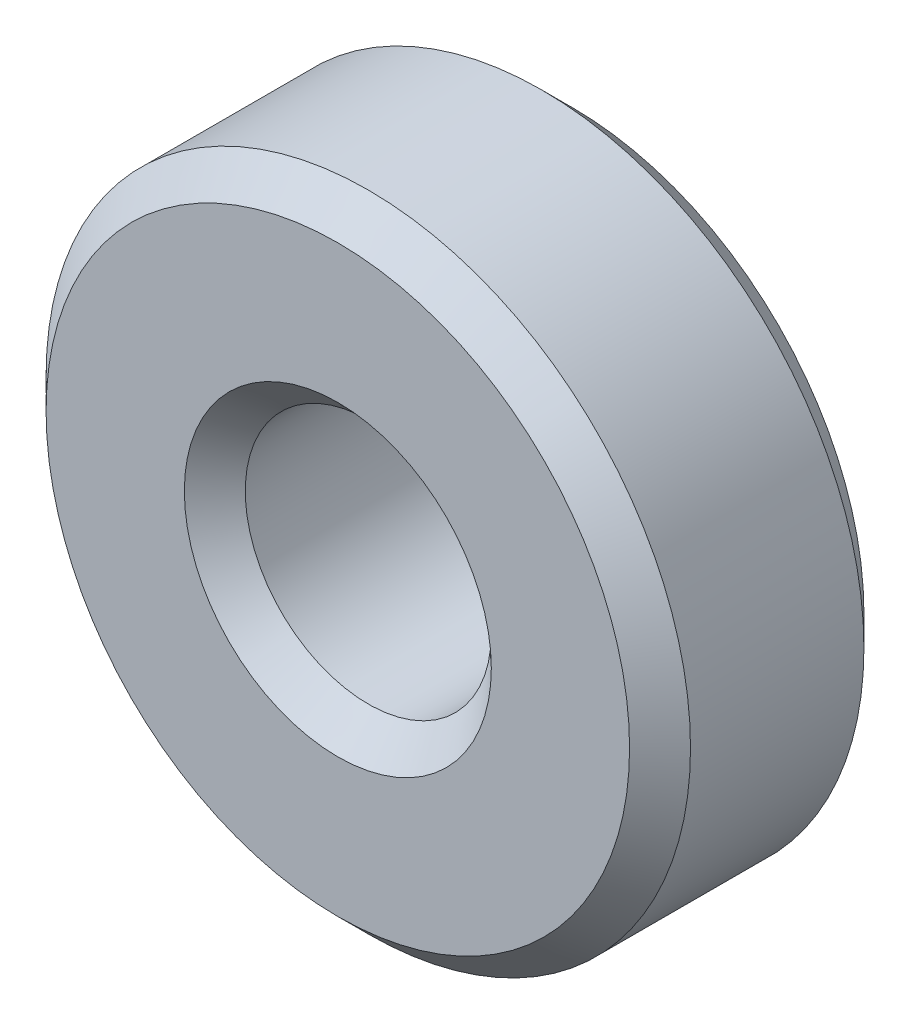
from build123d import *

# Parameters (mm, degrees)
SKETCH1_R           = 6.875
SKETCH1_R_2         = 2.625
BOSS_EXTRUDE1_DEPTH = 5
CHAMFER1_SIZE       = 0.65


with BuildPart() as part:
    # Sketch1 → Boss-Extrude1 (new body)
    with BuildSketch(Plane.XY):
        Circle(SKETCH1_R)
        Circle(SKETCH1_R_2, mode=Mode.SUBTRACT)
    extrude(amount=BOSS_EXTRUDE1_DEPTH)

    # Chamfer1
    chamfer1_edges = [part.edges().sort_by_distance(p)[0] for p in [
        (-6.875, 0, 0),
        (-6.875, 0, 5),
        (-2.625, 0, 0),
        (-2.625, 0, 5),
    ]]
    chamfer(chamfer1_edges, length=CHAMFER1_SIZE)


solid = part.part
